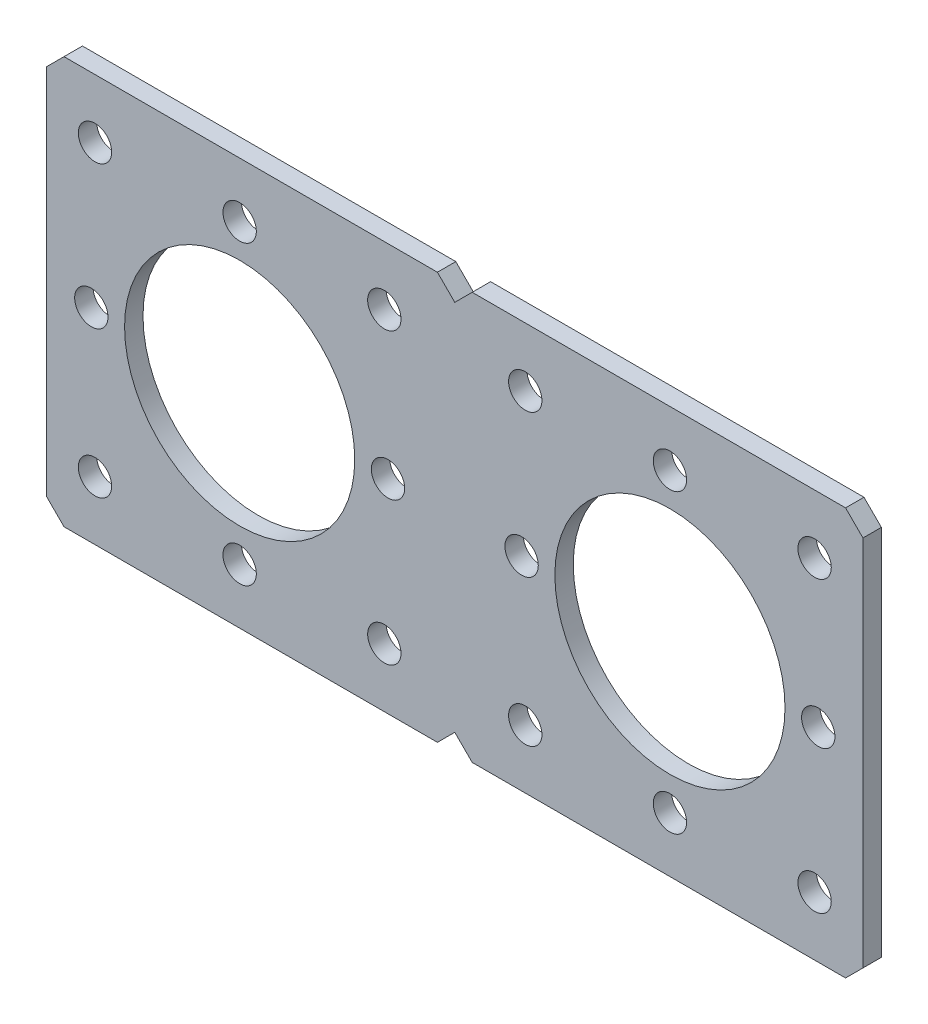
from build123d import *

# Parameters (mm, degrees)
SKETCH1_R           = 2.0701
SKETCH1_R_2         = 14.2875
BOSS_EXTRUDE1_DEPTH = 2.286


with BuildPart() as part:
    # Sketch1 → Boss-Extrude1 (new body)
    with BuildSketch(Plane(origin=(0, 0, 0), x_dir=(-1, 0, 0), z_dir=(0, 0, -1))):
        Polygon((0, -23.114), (2.159, -25.273), (48.514, -25.273), (50.673, -23.114), (50.673, 23.114), (48.514, 25.273), (2.159, 25.273), (0, 23.114), (-2.159, 25.273), (-48.514, 25.273), (-50.673, 23.114), (-50.673, -23.114), (-48.514, -25.273), (-2.159, -25.273), align=None)
        with Locations((26.7081, -18.415)):
            Circle(SKETCH1_R, mode=Mode.SUBTRACT)
        with Locations((-45.1231, 0)):
            Circle(SKETCH1_R, mode=Mode.SUBTRACT)
        with Locations((26.7081, 18.415)):
            Circle(SKETCH1_R, mode=Mode.SUBTRACT)
        with Locations((-26.7081, 18.415)):
            Circle(SKETCH1_R, mode=Mode.SUBTRACT)
        with Locations((8.747587758, 17.960512242)):
            Circle(SKETCH1_R, mode=Mode.SUBTRACT)
        with Locations((44.668612242, 17.960512242)):
            Circle(SKETCH1_R, mode=Mode.SUBTRACT)
        with Locations((26.7081, 0)):
            Circle(SKETCH1_R_2, mode=Mode.SUBTRACT)
        with Locations((-44.668612242, -17.960512242)):
            Circle(SKETCH1_R, mode=Mode.SUBTRACT)
        with Locations((-8.747587758, 17.960512242)):
            Circle(SKETCH1_R, mode=Mode.SUBTRACT)
        with Locations((-26.7081, 0)):
            Circle(SKETCH1_R_2, mode=Mode.SUBTRACT)
        with Locations((-8.747587758, -17.960512242)):
            Circle(SKETCH1_R, mode=Mode.SUBTRACT)
        with Locations((-44.668612242, 17.960512242)):
            Circle(SKETCH1_R, mode=Mode.SUBTRACT)
        with Locations((44.668612242, -17.960512242)):
            Circle(SKETCH1_R, mode=Mode.SUBTRACT)
        with Locations((8.747587758, -17.960512242)):
            Circle(SKETCH1_R, mode=Mode.SUBTRACT)
        with Locations((-8.2931, 0)):
            Circle(SKETCH1_R, mode=Mode.SUBTRACT)
        with Locations((45.1231, 0)):
            Circle(SKETCH1_R, mode=Mode.SUBTRACT)
        with Locations((8.2931, 0)):
            Circle(SKETCH1_R, mode=Mode.SUBTRACT)
        with Locations((-26.7081, -18.415)):
            Circle(SKETCH1_R, mode=Mode.SUBTRACT)
    extrude(amount=-BOSS_EXTRUDE1_DEPTH)


solid = part.part
